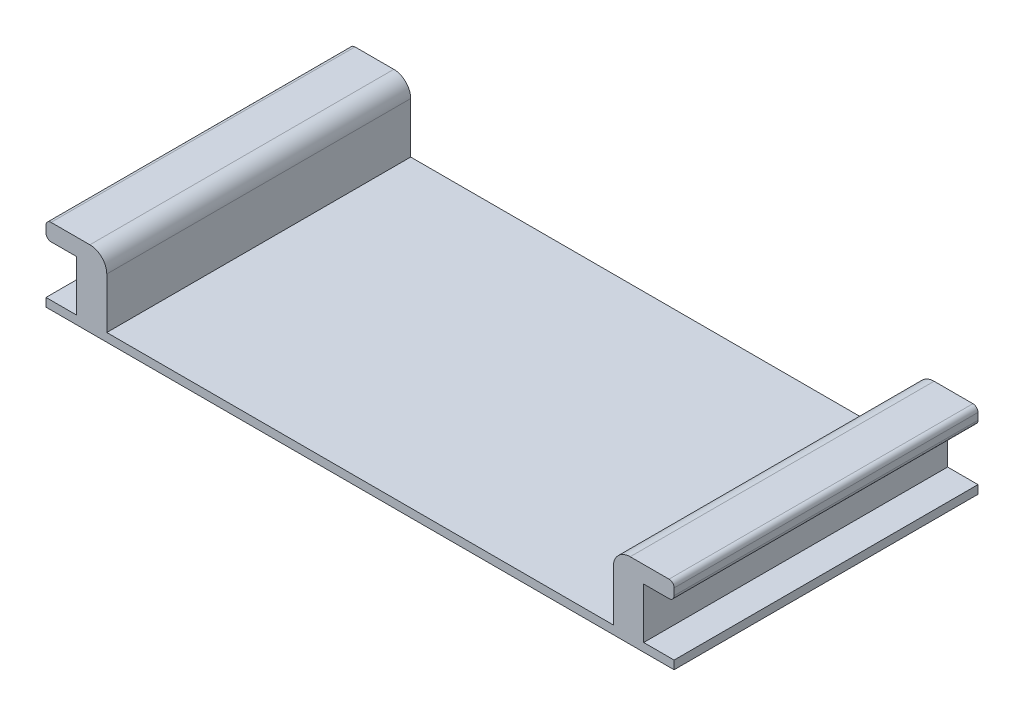
from build123d import *

# Parameters (mm, degrees)
BOSS_EXTRUDE1_DEPTH = 18
FILLET1_R           = 1
FILLET2_R           = 0.3


with BuildPart() as part:
    # Sketch1 → Boss-Extrude1 (new body)
    with BuildSketch(Plane.XY):
        Polygon((-15, 0), (-15, 4), (-18.6, 4), (-18.6, 3), (-16.8, 3), (-16.8, 0), (-18.6, 0), (-18.6, -0.5), (18.6, -0.5), (18.6, 0), (16.8, 0), (16.8, 3), (18.6, 3), (18.6, 4), (15, 4), (15, 0), align=None)
    extrude(amount=BOSS_EXTRUDE1_DEPTH)

    # Fillet1
    fillet1_edges = [part.edges().sort_by_distance(p)[0] for p in [
        (-15, 4, 9),
        (15, 4, 9),
    ]]
    fillet(fillet1_edges, radius=FILLET1_R)

    # Fillet2
    fillet2_edges = [part.edges().sort_by_distance(p)[0] for p in [
        (-18.6, 3, 9),
        (-18.6, 4, 9),
        (18.6, 4, 9),
        (18.6, 3, 9),
    ]]
    fillet(fillet2_edges, radius=FILLET2_R)


solid = part.part
